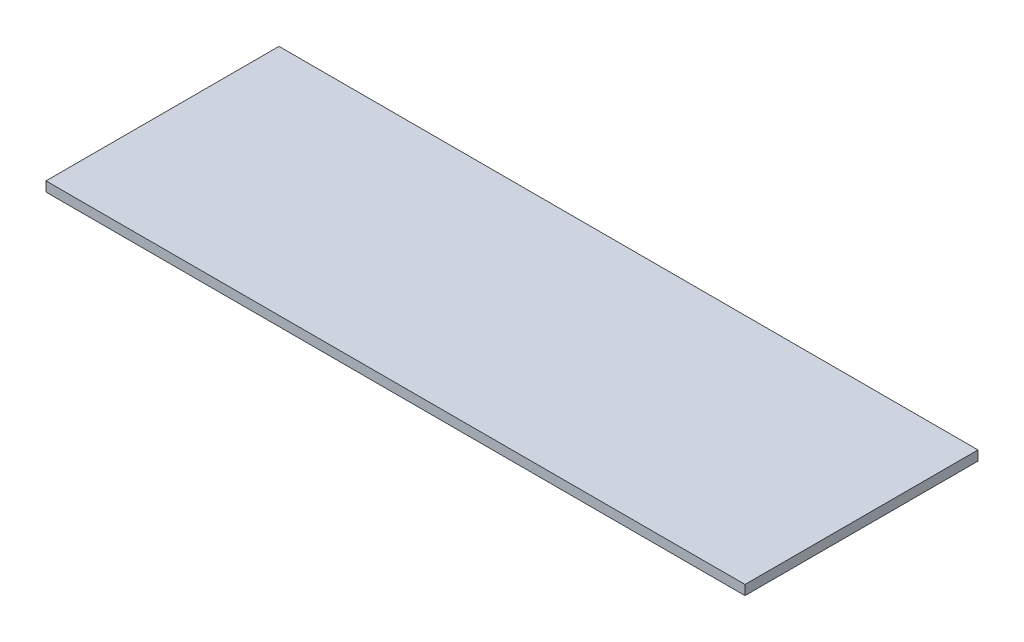
from build123d import *

# Parameters (mm, degrees)
SKETCH1_W           = 1800
SKETCH1_H           = 600
BOSS_EXTRUDE1_DEPTH = 25


with BuildPart() as part:
    # Sketch1 → Boss-Extrude1 (new body)
    with BuildSketch(Plane(origin=(0, 0, 0), x_dir=(1, 0, 0), z_dir=(0, 1, 0))):
        with Locations((5.341689834, 23.645305114)):
            Rectangle(SKETCH1_W, SKETCH1_H)
    extrude(amount=BOSS_EXTRUDE1_DEPTH)


solid = part.part
